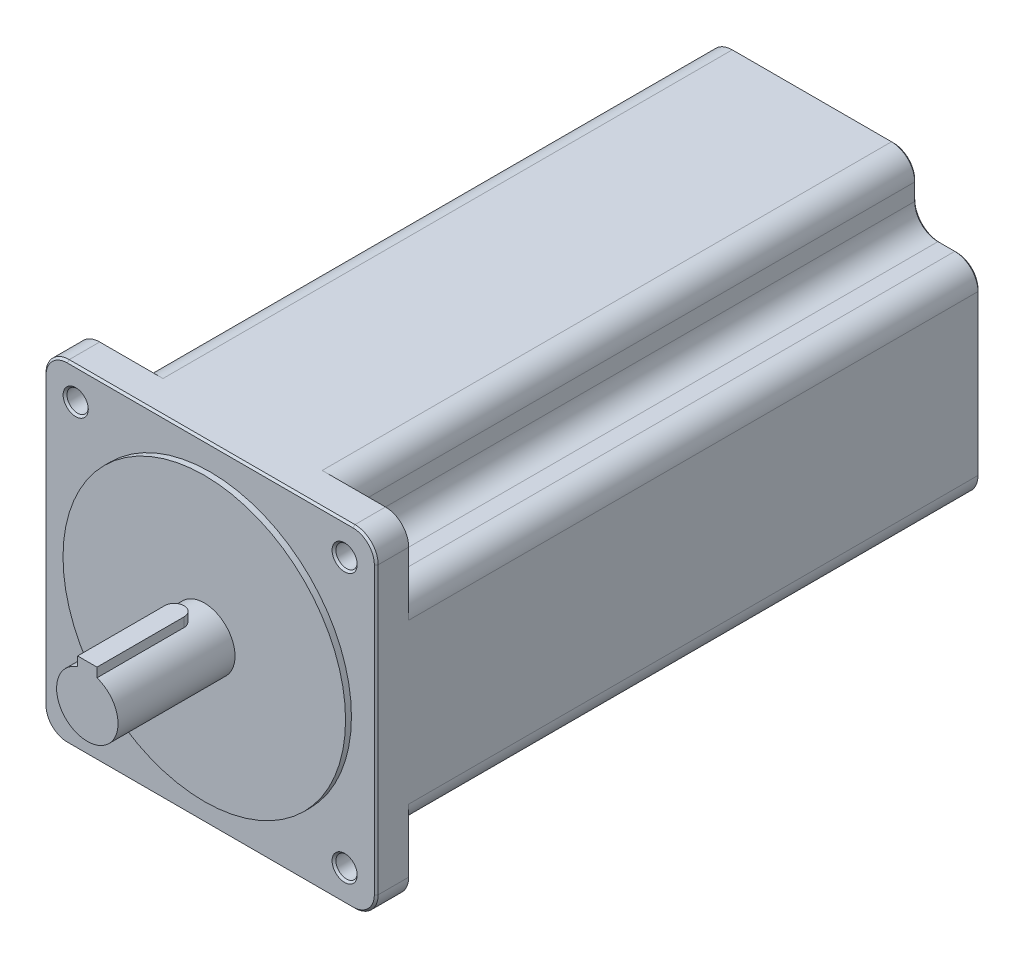
from build123d import *

# Parameters (mm, degrees)
SKETCH1_W                 = 85.85
SKETCH1_H                 = 85.85
BOSS_EXTRUDE1_DEPTH       = 8.38
BOSS_EXTRUDE3_DEPTH       = 147.62
FILLET4_R                 = 6
FILLET5_R                 = 6
SKETCH4_R                 = 36.51
BOSS_EXTRUDE4_DEPTH       = 1.52
SKETCH5_R                 = 7.9375
BOSS_EXTRUDE5_DEPTH       = 30.23
BOSS_EXTRUDE6_DEPTH       = 5
F_5_0MM_DOWEL_HOLE1_D     = 5.5
F_5_0MM_DOWEL_HOLE1_DEPTH = 8.38
CHAMFER1_SIZE             = 0.5


with BuildPart() as part:
    # Sketch1 → Boss-Extrude1 (new body)
    with BuildSketch(Plane.XY):
        Rectangle(SKETCH1_W, SKETCH1_H)
    extrude(amount=-BOSS_EXTRUDE1_DEPTH)

    # Sketch2 → Boss-Extrude3 (add)
    with BuildSketch(Plane(origin=(0, 0, -8.38), x_dir=(-1, 0, 0), z_dir=(0, 0, -1))):
        Polygon((-26.575, -42.925), (26.575, -42.925), (26.575, -26.575), (42.925, -26.575), (42.925, 26.575), (26.575, 26.575), (26.575, 42.925), (-26.575, 42.925), (-26.575, 26.575), (-42.925, 26.575), (-42.925, -26.575), (-26.575, -26.575), align=None)
    extrude(amount=BOSS_EXTRUDE3_DEPTH)

    # Fillet4
    fillet4_edges = [part.edges().sort_by_distance(p)[0] for p in [
        (42.925, -26.575, -82.19),
        (26.575, -26.575, -82.19),
        (26.575, -42.925, -82.19),
        (-26.575, -42.925, -82.19),
        (-26.575, -26.575, -82.19),
        (-42.925, -26.575, -82.19),
        (-42.925, 26.575, -82.19),
        (-26.575, 26.575, -82.19),
        (-26.575, 42.925, -82.19),
        (26.575, 42.925, -82.19),
        (26.575, 26.575, -82.19),
        (42.925, 26.575, -82.19),
    ]]
    fillet(fillet4_edges, radius=FILLET4_R)

    # Fillet5
    fillet5_edges = [part.edges().sort_by_distance(p)[0] for p in [
        (-42.925, -42.925, -4.19),
        (42.925, -42.925, -4.19),
        (42.925, 42.925, -4.19),
        (-42.925, 42.925, -4.19),
    ]]
    fillet(fillet5_edges, radius=FILLET5_R)

    # Sketch4 → Boss-Extrude4 (add)
    with BuildSketch(Plane.XY):
        Circle(SKETCH4_R)
    extrude(amount=BOSS_EXTRUDE4_DEPTH)

    # Sketch5 → Boss-Extrude5 (add)
    with BuildSketch(Plane.XY.offset(1.52)):
        Circle(SKETCH5_R)
    extrude(amount=BOSS_EXTRUDE5_DEPTH)

    # Sketch6 → Boss-Extrude6 (add)
    with BuildSketch(Plane(origin=(0, 9.9375, 0), x_dir=(1, 0, 0), z_dir=(0, 1, 0))):
        with BuildLine():
            Line((-2.5, -31.75), (2.5, -31.75))
            Line((2.5, -31.75), (2.5, -9.25))
            ThreePointArc((2.5, -9.25), (0, -6.75), (-2.5, -9.25))
            Line((-2.5, -9.25), (-2.5, -31.75))
        make_face()
    extrude(amount=-BOSS_EXTRUDE6_DEPTH)

    # Ø5.0mm Dowel Hole1
    with Locations(Plane.XY):
        with Locations((-34.75, 34.75), (34.75, 34.75), (34.75, -34.75), (-34.75, -34.75)):
            Hole(F_5_0MM_DOWEL_HOLE1_D / 2, depth=F_5_0MM_DOWEL_HOLE1_DEPTH)

    # Chamfer1
    chamfer1_edges = [part.edges().sort_by_distance(p)[0] for p in [
        (-42.925, 0, 0),
        (42.925, 0, 0),
        (0, 42.925, 0),
        (0, -42.925, 0),
        (-41.167640687, 41.167640687, 0),
        (41.167640687, 41.167640687, 0),
        (41.167640687, -41.167640687, 0),
        (-41.167640687, -41.167640687, 0),
        (-32, -34.75, 0),
        (-32, -34.75, -8.38),
        (37.5, -34.75, 0),
        (37.5, -34.75, -8.38),
        (37.5, 34.75, 0),
        (37.5, 34.75, -8.38),
        (-32, 34.75, 0),
        (-32, 34.75, -8.38),
        (34.75, -26.575, -156),
        (42.925, 0, -156),
        (26.575, 34.75, -156),
        (34.75, 26.575, -156),
        (26.575, -34.75, -156),
        (0, -42.925, -156),
        (-26.575, -34.75, -156),
        (-34.75, -26.575, -156),
        (-42.925, 0, -156),
        (-34.75, 26.575, -156),
        (-26.575, 34.75, -156),
        (0, 42.925, -156),
        (41.167640687, 24.817640687, -156),
        (24.817640687, 41.167640687, -156),
        (-24.817640687, 41.167640687, -156),
        (-41.167640687, 24.817640687, -156),
        (-41.167640687, -24.817640687, -156),
        (-24.817640687, -41.167640687, -156),
        (24.817640687, -41.167640687, -156),
        (41.167640687, -24.817640687, -156),
        (28.332359313, -28.332359313, -156),
        (-28.332359313, -28.332359313, -156),
        (-28.332359313, 28.332359313, -156),
        (28.332359313, 28.332359313, -156),
    ]]
    chamfer(chamfer1_edges, length=CHAMFER1_SIZE)


solid = part.part
